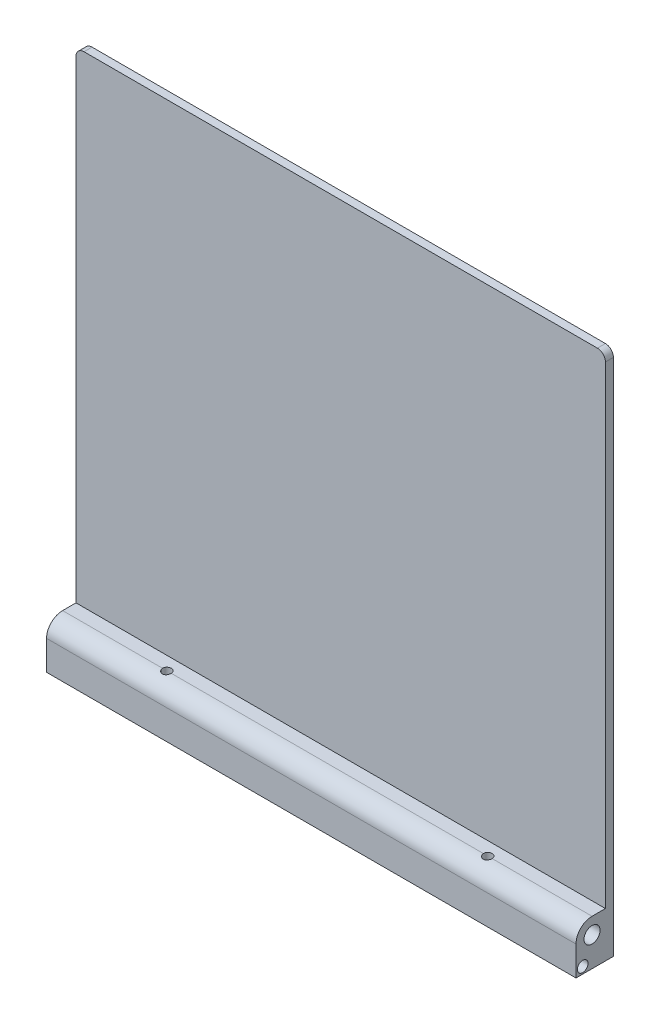
from build123d import *

# Parameters (mm, degrees)
SKETCH1_W           = 198
SKETCH1_H           = 180
BOSS_EXTRUDE1_DEPTH = 3
SKETCH3_R           = 3
BOSS_EXTRUDE2_DEPTH = 198
SKETCH12_R          = 1.65
CUT_EXTRUDE1_DEPTH  = 5
SKETCH4_W           = 198
SKETCH4_H           = 3
BOSS_EXTRUDE3_DEPTH = 17
SKETCH10_W          = 198
SKETCH10_H          = 2
BOSS_EXTRUDE7_DEPTH = 10
FILLET2_R           = 3
BOSS_EXTRUDE8_DEPTH = 198
SKETCH15_R          = 2
CUT_EXTRUDE4_DEPTH  = 4


with BuildPart() as part:
    # Sketch1 → Boss-Extrude1 (new body)
    with BuildSketch(Plane.XY):
        with Locations((99, 90)):
            Rectangle(SKETCH1_W, SKETCH1_H)
    extrude(amount=BOSS_EXTRUDE1_DEPTH)

    # Sketch3 → Boss-Extrude2 (add)
    with BuildSketch(Plane.ZY):
        with BuildLine():
            Line((0, 0), (8, 0))
            ThreePointArc((8, 0), (14, -6), (8, -12))
            Line((8, -12), (0, -12))
            Line((0, -12), (0, 0))
        make_face()
        with Locations((8, -6)):
            Circle(SKETCH3_R, mode=Mode.SUBTRACT)
    extrude(amount=-BOSS_EXTRUDE2_DEPTH)

    # Sketch12 → Cut-Extrude1 (cut)
    with BuildSketch(Plane(origin=(0, 0, 0), x_dir=(1, 0, 0), z_dir=(0, 1, 0))):
        with Locations((39, -8)):
            Circle(SKETCH12_R)
        with Locations((159, -8)):
            Circle(SKETCH12_R)
    extrude(amount=-CUT_EXTRUDE1_DEPTH, mode=Mode.SUBTRACT)

    # Sketch4 → Boss-Extrude3 (add)
    with BuildSketch(Plane.XZ):
        with Locations((99, 1.5)):
            Rectangle(SKETCH4_W, SKETCH4_H)
    extrude(amount=BOSS_EXTRUDE3_DEPTH)

    # Sketch10 → Boss-Extrude7 (add)
    with BuildSketch(Plane.XY.offset(3)):
        with Locations((99, -16)):
            Rectangle(SKETCH10_W, SKETCH10_H)
    extrude(amount=BOSS_EXTRUDE7_DEPTH)

    # Fillet2
    fillet2_edges = [part.edges().sort_by_distance(p)[0] for p in [
        (198, 180, 1.5),
        (0, 180, 1.5),
        (0, -17, 6.5),
        (198, -17, 6.5),
    ]]
    fillet(fillet2_edges, radius=FILLET2_R)

    # Sketch11 → Boss-Extrude8 (add)
    with BuildSketch(Plane.ZY):
        with BuildLine():
            Line((11, -6), (14, -6))
            Line((14, -6), (14, -17))
            Line((14, -17), (0, -17))
            Line((0, -17), (0, -6))
            Line((0, -6), (5, -6))
            ThreePointArc((5, -6), (8, -9), (11, -6))
        make_face()
    extrude(amount=-BOSS_EXTRUDE8_DEPTH)

    # Sketch15 → Cut-Extrude4 (cut)
    with BuildSketch(Plane(origin=(198, 0, 0), x_dir=(0, 0, -1), z_dir=(1, 0, 0))):
        with Locations((-11.5, -14.5)):
            Circle(SKETCH15_R)
    cut_extrude4 = extrude(amount=-CUT_EXTRUDE4_DEPTH, mode=Mode.SUBTRACT)

    # Mirror3: Cut-Extrude4 across plane
    add(cut_extrude4.mirror(Plane.ZY.offset(-99)), mode=Mode.SUBTRACT)


solid = part.part
